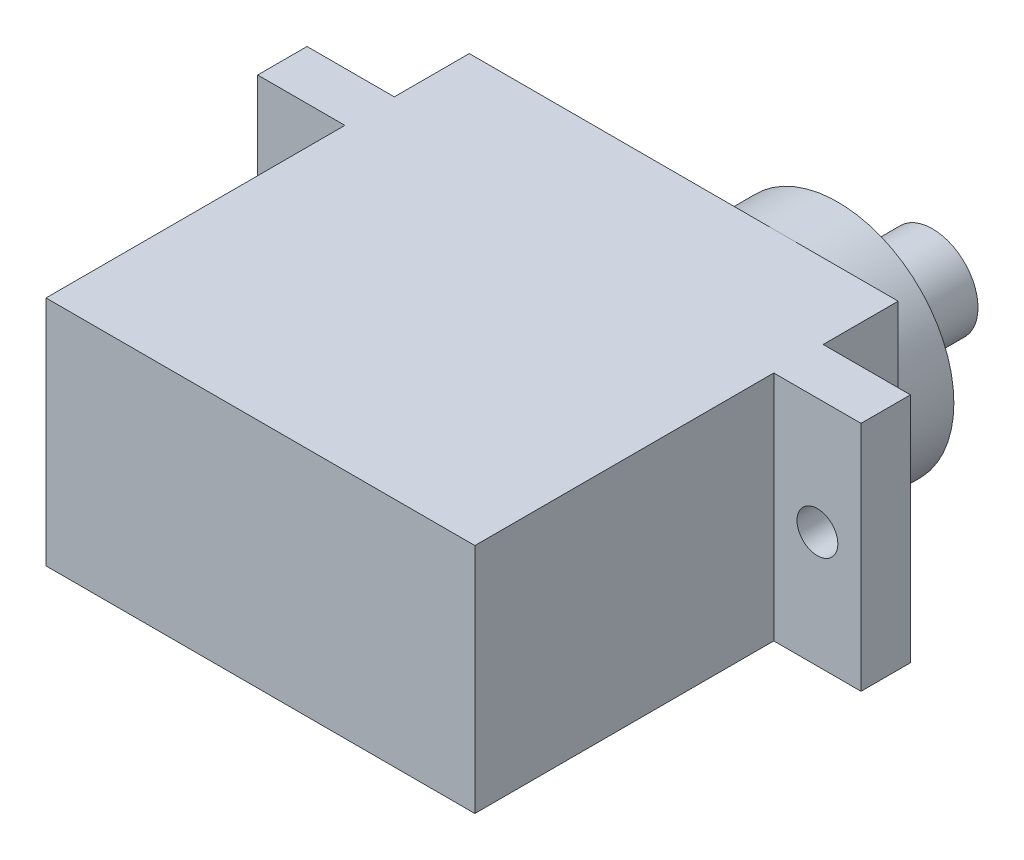
from build123d import *

# Parameters (mm, degrees)
SKETCH_1_R          = 6.25
SKETCH_1_R_2        = 2.45
EXTRUDE_1_DEPTH     = 16.1
SKETCH_1_3_W        = 32.5
SKETCH_1_3_H        = 12.5
EXTRUDE_2_DEPTH     = 2.66
SKETCH_1_4_R        = 6.25
SKETCH_1_4_R_2      = 2.45
SKETCH_1_4_W        = 23.1
SKETCH_1_4_H        = 12.5
EXTRUDE_3_DEPTH     = 6.7
SKETCH_1_5_R        = 6.25
EXTRUDE_4_DEPTH     = 9.7
SKETCH_1_6_R        = 2.45
EXTRUDE_5_DEPTH     = 14.8
SKETCH_3_R          = 1.1
CUT_EXTRUDE_1_DEPTH = 14.8
SKETCH_2_R          = 1.1
CUT_EXTRUDE_2_DEPTH = 14.8


with BuildPart() as part:
    # 草图1 → 凸台-拉伸1 (new body)
    with BuildSketch(Plane.XY):
        with BuildLine():
            Line((4.7, 12.5), (4.7, 0))
            Line((4.7, 0), (21.55, 0))
            ThreePointArc((21.55, 0), (15.3, 6.25), (21.55, 12.5))
            Line((21.55, 12.5), (4.7, 12.5))
        make_face()
        with BuildLine():
            Line((27.8, 12.5), (21.55, 12.5))
            ThreePointArc((21.55, 12.5), (25.969417382, 10.669417382), (27.8, 6.25))
            Line((27.8, 6.25), (27.8, 12.5))
        make_face()
        with BuildLine():
            ThreePointArc((27.8, 6.25), (25.969417382, 1.830582618), (21.55, 0))
            Line((21.55, 0), (27.8, 0))
            Line((27.8, 0), (27.8, 6.25))
        make_face()
        with Locations((21.55, 6.25)):
            Circle(SKETCH_1_R)
        with Locations((21.55, 6.25)):
            Circle(SKETCH_1_R_2, mode=Mode.SUBTRACT)
        with Locations((21.55, 6.25)):
            Circle(SKETCH_1_R_2)
    extrude(amount=EXTRUDE_1_DEPTH)

    # 草图1<3> → 凸台-拉伸2 (add)
    with BuildSketch(Plane.XY):
        with Locations((16.25, 6.25)):
            Rectangle(SKETCH_1_3_W, SKETCH_1_3_H)
    extrude(amount=-EXTRUDE_2_DEPTH)

    # 草图1<4> → 凸台-拉伸3 (add)
    with BuildSketch(Plane.XY):
        with Locations((21.55, 6.25)):
            Circle(SKETCH_1_4_R)
        with Locations((21.55, 6.25)):
            Circle(SKETCH_1_4_R_2, mode=Mode.SUBTRACT)
        with Locations((16.25, 6.25)):
            Rectangle(SKETCH_1_4_W, SKETCH_1_4_H)
    extrude(amount=-EXTRUDE_3_DEPTH)

    # 草图1<5> → 凸台-拉伸4 (add)
    with BuildSketch(Plane.XY):
        with Locations((21.55, 6.25)):
            Circle(SKETCH_1_5_R)
    extrude(amount=-EXTRUDE_4_DEPTH)

    # 草图1<6> → 凸台-拉伸5 (add)
    with BuildSketch(Plane.XY):
        with Locations((21.55, 6.25)):
            Circle(SKETCH_1_6_R)
    extrude(amount=-EXTRUDE_5_DEPTH)

    # 草图3 → 切除-拉伸1 (cut)
    with BuildSketch(Plane(origin=(0, 0, -2.66), x_dir=(-1, 0, 0), z_dir=(0, 0, -1))):
        with Locations((-2.12941164, 6.25)):
            Circle(SKETCH_3_R)
    extrude(amount=-CUT_EXTRUDE_1_DEPTH, mode=Mode.SUBTRACT)

    # 草图2 → 切除-拉伸2 (cut)
    with BuildSketch(Plane(origin=(0, 0, -2.66), x_dir=(-1, 0, 0), z_dir=(0, 0, -1))):
        with Locations((-30.15, 6.25)):
            Circle(SKETCH_2_R)
    extrude(amount=-CUT_EXTRUDE_2_DEPTH, mode=Mode.SUBTRACT)


solid = part.part
